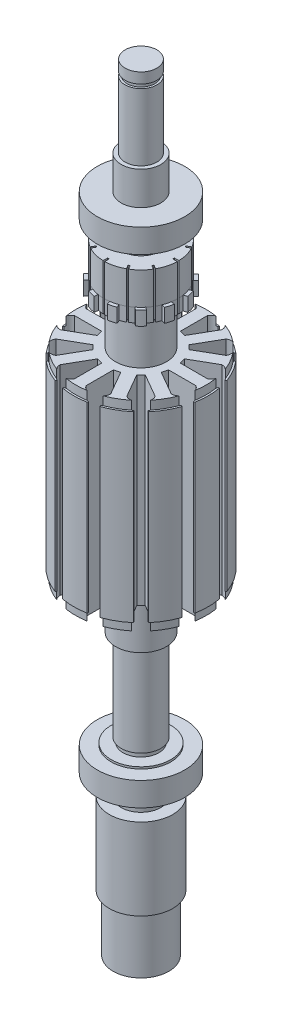
from build123d import *

# Parameters (mm, degrees)
CORTAR_EXTRUIR1_DEPTH  = 12
CORTAR_EXTRUIR9_START  = -3.5
CORTAR_EXTRUIR9_DEPTH  = 3.5
CORTAR_EXTRUIR10_REACH = 134.6


with BuildPart() as part:
    # Croquis1 → Revolución1 (revolve)
    with BuildSketch(Plane.XY):
        Polygon((0, 101.460505057), (-4, 101.460505057), (-4, 98.810505057), (-3.5, 98.810505057), (-3.5, 97.810505057), (-4, 97.810505057), (-4, 80.960505057), (-5, 80.960505057), (-5, 72.560505057), (-11, 72.560505057), (-11, 66.560505057), (-8, 66.560505057), (-8, 65.560505057), (-5, 65.560505057), (-4.5, 65.560505057), (-4.5, 64.360505057), (-5, 64.360505057), (-5, 62.060505057), (-9.35, 62.060505057), (-9.35, 53.910505057), (-10.25, 53.910505057), (-10.25, 50.410505057), (-6.4, 50.410505057), (-6.4, 38.610505057), (-16.45, 38.610505057), (-16.45, 36.460505057), (-16.925, 36.460505057), (-16.925, -9.539494943), (-16.45, -9.539494943), (-16.45, -11.689494943), (-6.4, -11.689494943), (-6.4, -23.489494943), (-5, -23.489494943), (-5, -46.389494943), (-4.5, -46.389494943), (-4.5, -47.589494943), (-5, -47.589494943), (-7.5, -47.589494943), (-7.5, -48.089494943), (-11, -48.089494943), (-11, -54.089494943), (-5, -54.089494943), (-5, -59.289494943), (-8, -59.289494943), (-8, -79.789494943), (-7.016666436, -79.789494943), (-7.016666436, -93.989494943), (-6.624118991, -93.989494943), (-2.282859875, -76.362612781), (0, -76.362612781), align=None)
    revolve(axis=Axis((0, -76.362612781, 0), (0, 1, 0)))

    # Croquis2 → Cortar-Extruir1 (cut)
    with BuildSketch(Plane(origin=(0, 62.060505057, 0), x_dir=(1, 0, 0), z_dir=(0, 1, 0))):
        with BuildLine():
            Line((-0.2, 11.998333218), (-0.2, 8.197560613))
            Line((-0.2, 8.197560613), (0.2, 8.197560613))
            Line((0.2, 8.197560613), (0.2, 11.998333218))
            ThreePointArc((0.2, 11.998333218), (0, 12), (-0.2, 11.998333218))
        make_face()
        with BuildLine():
            Line((4.271985387, 6.99929574), (6.17237169, 10.290861369))
            ThreePointArc((6.17237169, 10.290861369), (6, 10.392304845), (5.825961528, 10.490861369))
            Line((5.825961528, 10.490861369), (3.925575226, 7.19929574))
            Line((3.925575226, 7.19929574), (4.271985387, 6.99929574))
        make_face()
        with BuildLine():
            Line((7.19929574, 3.925575226), (10.490861369, 5.825961528))
            ThreePointArc((10.490861369, 5.825961528), (10.392304845, 6), (10.290861369, 6.17237169))
            Line((10.290861369, 6.17237169), (6.99929574, 4.271985387))
            Line((6.99929574, 4.271985387), (7.19929574, 3.925575226))
        make_face()
        with BuildLine():
            Line((8.197560613, -0.2), (11.998333218, -0.2))
            ThreePointArc((11.998333218, -0.2), (12, 0), (11.998333218, 0.2))
            Line((11.998333218, 0.2), (8.197560613, 0.2))
            Line((8.197560613, 0.2), (8.197560613, -0.2))
        make_face()
        with BuildLine():
            Line((6.99929574, -4.271985387), (10.290861369, -6.17237169))
            ThreePointArc((10.290861369, -6.17237169), (10.392304845, -6), (10.490861369, -5.825961528))
            Line((10.490861369, -5.825961528), (7.19929574, -3.925575226))
            Line((7.19929574, -3.925575226), (6.99929574, -4.271985387))
        make_face()
        with BuildLine():
            Line((3.925575226, -7.19929574), (5.825961528, -10.490861369))
            ThreePointArc((5.825961528, -10.490861369), (6, -10.392304845), (6.17237169, -10.290861369))
            Line((6.17237169, -10.290861369), (4.271985387, -6.99929574))
            Line((4.271985387, -6.99929574), (3.925575226, -7.19929574))
        make_face()
        with BuildLine():
            Line((-0.2, -8.197560613), (-0.2, -11.998333218))
            ThreePointArc((-0.2, -11.998333218), (0, -12), (0.2, -11.998333218))
            Line((0.2, -11.998333218), (0.2, -8.197560613))
            Line((0.2, -8.197560613), (-0.2, -8.197560613))
        make_face()
        with BuildLine():
            Line((-4.271985387, -6.99929574), (-6.17237169, -10.290861369))
            ThreePointArc((-6.17237169, -10.290861369), (-6, -10.392304845), (-5.825961528, -10.490861369))
            Line((-5.825961528, -10.490861369), (-3.925575226, -7.19929574))
            Line((-3.925575226, -7.19929574), (-4.271985387, -6.99929574))
        make_face()
        with BuildLine():
            Line((-7.19929574, -3.925575226), (-10.490861369, -5.825961528))
            ThreePointArc((-10.490861369, -5.825961528), (-10.392304845, -6), (-10.290861369, -6.17237169))
            Line((-10.290861369, -6.17237169), (-6.99929574, -4.271985387))
            Line((-6.99929574, -4.271985387), (-7.19929574, -3.925575226))
        make_face()
        with BuildLine():
            Line((-8.197560613, 0.2), (-11.998333218, 0.2))
            ThreePointArc((-11.998333218, 0.2), (-12, 0), (-11.998333218, -0.2))
            Line((-11.998333218, -0.2), (-8.197560613, -0.2))
            Line((-8.197560613, -0.2), (-8.197560613, 0.2))
        make_face()
        with BuildLine():
            Line((-6.99929574, 4.271985387), (-10.290861369, 6.17237169))
            ThreePointArc((-10.290861369, 6.17237169), (-10.392304845, 6), (-10.490861369, 5.825961528))
            Line((-10.490861369, 5.825961528), (-7.19929574, 3.925575226))
            Line((-7.19929574, 3.925575226), (-6.99929574, 4.271985387))
        make_face()
        with BuildLine():
            Line((-3.925575226, 7.19929574), (-5.825961528, 10.490861369))
            ThreePointArc((-5.825961528, 10.490861369), (-6, 10.392304845), (-6.17237169, 10.290861369))
            Line((-6.17237169, 10.290861369), (-4.271985387, 6.99929574))
            Line((-4.271985387, 6.99929574), (-3.925575226, 7.19929574))
        make_face()
    extrude(amount=-CORTAR_EXTRUIR1_DEPTH, mode=Mode.SUBTRACT)

    # Croquis4 → Cortar-Extruir9 (cut)
    with BuildSketch(Plane(origin=(0, 53.910505057, 0), x_dir=(1, 0, 0), z_dir=(0, 1, 0)).offset(CORTAR_EXTRUIR9_START)):
        with BuildLine():
            Line((1.705844329, 10.23000101), (1.564388643, 9.155538401))
            Line((1.564388643, 9.155538401), (0.118732796, 9.345862604))
            Line((0.118732796, 9.345862604), (0.118732796, 11.707018854))
            Line((0.118732796, 11.707018854), (5.927642229, 10.34859183))
            Line((5.927642229, 10.34859183), (4.648844458, 8.116042081))
            Line((4.648844458, 8.116042081), (3.394817677, 8.636964311))
            Line((3.394817677, 8.636964311), (3.70532732, 9.964766513))
            ThreePointArc((3.70532732, 9.964766513), (2.762797192, 10.528674406), (1.705844329, 10.23000101))
        make_face()
        with BuildLine():
            Line((4.77575692, 8.034388037), (5.956335045, 10.079209332))
            Line((5.956335045, 10.079209332), (10.30778467, 5.998322304))
            Line((10.30778467, 5.998322304), (8.084038439, 4.704276392))
            Line((8.084038439, 4.704276392), (7.258480505, 5.782421666))
            Line((7.258480505, 5.782421666), (8.191290845, 6.777077283))
            ThreePointArc((8.191290845, 6.777077283), (7.656989757, 7.736700908), (6.592305028, 8.006518591))
            Line((6.592305028, 8.006518591), (5.932569507, 7.14673452))
            Line((5.932569507, 7.14673452), (4.77575692, 8.034388037))
        make_face()
        with BuildLine():
            Line((8.153120834, 4.570105684), (10.197942129, 5.750683809))
            Line((10.197942129, 5.750683809), (11.925964533, 0.04080716))
            Line((11.925964533, 0.04080716), (9.35312085, 0.032003642))
            Line((9.35312085, 0.032003642), (9.177239343, 1.378483806))
            Line((9.177239343, 1.378483806), (10.482404603, 1.773475668))
            ThreePointArc((10.482404603, 1.773475668), (10.4994981, 2.871684649), (9.712362919, 3.637695981))
            Line((9.712362919, 3.637695981), (8.711123162, 3.222968895))
            Line((8.711123162, 3.222968895), (8.153120834, 4.570105684))
        make_face()
        with BuildLine():
            Line((9.345862604, -0.118732796), (11.707018854, -0.118732796))
            Line((11.707018854, -0.118732796), (10.34859183, -5.927642229))
            Line((10.34859183, -5.927642229), (8.116042081, -4.648844458))
            Line((8.116042081, -4.648844458), (8.636964311, -3.394817677))
            Line((8.636964311, -3.394817677), (9.964766513, -3.70532732))
            ThreePointArc((9.964766513, -3.70532732), (10.528674406, -2.762797192), (10.23000101, -1.705844329))
            Line((10.23000101, -1.705844329), (9.155538401, -1.564388643))
            Line((9.155538401, -1.564388643), (9.345862604, -0.118732796))
        make_face()
        with BuildLine():
            Line((8.034388037, -4.77575692), (10.079209332, -5.956335045))
            Line((10.079209332, -5.956335045), (5.998322304, -10.30778467))
            Line((5.998322304, -10.30778467), (4.704276392, -8.084038439))
            Line((4.704276392, -8.084038439), (5.782421666, -7.258480505))
            Line((5.782421666, -7.258480505), (6.777077283, -8.191290845))
            ThreePointArc((6.777077283, -8.191290845), (7.736700908, -7.656989757), (8.006518591, -6.592305028))
            Line((8.006518591, -6.592305028), (7.14673452, -5.932569507))
            Line((7.14673452, -5.932569507), (8.034388037, -4.77575692))
        make_face()
        with BuildLine():
            Line((4.570105684, -8.153120834), (5.750683809, -10.197942129))
            Line((5.750683809, -10.197942129), (0.04080716, -11.925964533))
            Line((0.04080716, -11.925964533), (0.032003642, -9.35312085))
            Line((0.032003642, -9.35312085), (1.378483806, -9.177239343))
            Line((1.378483806, -9.177239343), (1.773475668, -10.482404603))
            ThreePointArc((1.773475668, -10.482404603), (2.871684649, -10.4994981), (3.637695981, -9.712362919))
            Line((3.637695981, -9.712362919), (3.222968895, -8.711123162))
            Line((3.222968895, -8.711123162), (4.570105684, -8.153120834))
        make_face()
        with BuildLine():
            Line((-0.118732796, -9.345862604), (-0.118732796, -11.707018854))
            Line((-0.118732796, -11.707018854), (-5.927642229, -10.34859183))
            Line((-5.927642229, -10.34859183), (-4.648844458, -8.116042081))
            Line((-4.648844458, -8.116042081), (-3.394817677, -8.636964311))
            Line((-3.394817677, -8.636964311), (-3.70532732, -9.964766513))
            ThreePointArc((-3.70532732, -9.964766513), (-2.762797192, -10.528674406), (-1.705844329, -10.23000101))
            Line((-1.705844329, -10.23000101), (-1.564388643, -9.155538401))
            Line((-1.564388643, -9.155538401), (-0.118732796, -9.345862604))
        make_face()
        with BuildLine():
            Line((-4.77575692, -8.034388037), (-5.956335045, -10.079209332))
            Line((-5.956335045, -10.079209332), (-10.30778467, -5.998322304))
            Line((-10.30778467, -5.998322304), (-8.084038439, -4.704276392))
            Line((-8.084038439, -4.704276392), (-7.258480505, -5.782421666))
            Line((-7.258480505, -5.782421666), (-8.191290845, -6.777077283))
            ThreePointArc((-8.191290845, -6.777077283), (-7.656989757, -7.736700908), (-6.592305028, -8.006518591))
            Line((-6.592305028, -8.006518591), (-5.932569507, -7.14673452))
            Line((-5.932569507, -7.14673452), (-4.77575692, -8.034388037))
        make_face()
        with BuildLine():
            Line((-8.153120834, -4.570105684), (-10.197942129, -5.750683809))
            Line((-10.197942129, -5.750683809), (-11.925964533, -0.04080716))
            Line((-11.925964533, -0.04080716), (-9.35312085, -0.032003642))
            Line((-9.35312085, -0.032003642), (-9.177239343, -1.378483806))
            Line((-9.177239343, -1.378483806), (-10.482404603, -1.773475668))
            ThreePointArc((-10.482404603, -1.773475668), (-10.4994981, -2.871684649), (-9.712362919, -3.637695981))
            Line((-9.712362919, -3.637695981), (-8.711123162, -3.222968895))
            Line((-8.711123162, -3.222968895), (-8.153120834, -4.570105684))
        make_face()
        with BuildLine():
            Line((-9.345862604, 0.118732796), (-11.707018854, 0.118732796))
            Line((-11.707018854, 0.118732796), (-10.34859183, 5.927642229))
            Line((-10.34859183, 5.927642229), (-8.116042081, 4.648844458))
            Line((-8.116042081, 4.648844458), (-8.636964311, 3.394817677))
            Line((-8.636964311, 3.394817677), (-9.964766513, 3.70532732))
            ThreePointArc((-9.964766513, 3.70532732), (-10.528674406, 2.762797192), (-10.23000101, 1.705844329))
            Line((-10.23000101, 1.705844329), (-9.155538401, 1.564388643))
            Line((-9.155538401, 1.564388643), (-9.345862604, 0.118732796))
        make_face()
        with BuildLine():
            Line((-8.034388037, 4.77575692), (-10.079209332, 5.956335045))
            Line((-10.079209332, 5.956335045), (-5.998322304, 10.30778467))
            Line((-5.998322304, 10.30778467), (-4.704276392, 8.084038439))
            Line((-4.704276392, 8.084038439), (-5.782421666, 7.258480505))
            Line((-5.782421666, 7.258480505), (-6.777077283, 8.191290845))
            ThreePointArc((-6.777077283, 8.191290845), (-7.736700908, 7.656989757), (-8.006518591, 6.592305028))
            Line((-8.006518591, 6.592305028), (-7.14673452, 5.932569507))
            Line((-7.14673452, 5.932569507), (-8.034388037, 4.77575692))
        make_face()
        with BuildLine():
            Line((-4.570105684, 8.153120834), (-5.750683809, 10.197942129))
            Line((-5.750683809, 10.197942129), (-0.04080716, 11.925964533))
            Line((-0.04080716, 11.925964533), (-0.032003642, 9.35312085))
            Line((-0.032003642, 9.35312085), (-1.378483806, 9.177239343))
            Line((-1.378483806, 9.177239343), (-1.773475668, 10.482404603))
            ThreePointArc((-1.773475668, 10.482404603), (-2.871684649, 10.4994981), (-3.637695981, 9.712362919))
            Line((-3.637695981, 9.712362919), (-3.222968895, 8.711123162))
            Line((-3.222968895, 8.711123162), (-4.570105684, 8.153120834))
        make_face()
    extrude(amount=CORTAR_EXTRUIR9_DEPTH, mode=Mode.SUBTRACT)

    # Croquis5 → Cortar-Extruir10 (cut, up to next)
    with BuildSketch(Plane(origin=(0, 38.610505057, 0), x_dir=(1, 0, 0), z_dir=(0, 1, 0)), mode=Mode.PRIVATE) as cortar_extruir10_sk1:
        with BuildLine():
            Line((1.478196291, 8.432321249), (2.936005085, 8.04170256))
            Line((2.936005085, 8.04170256), (6.364406158, 13.979867409))
            ThreePointArc((6.364406158, 13.979867409), (6.150920992, 14.928970981), (5.513598767, 15.663949816))
            Line((5.513598767, 15.663949816), (5.63466054, 15.959518339))
            Line((5.63466054, 15.959518339), (5.513598767, 16.248550154))
            Line((5.513598767, 16.248550154), (3.30245082, 16.792756814))
            Line((3.30245082, 16.792756814), (3.1, 16.638678583))
            Line((3.1, 16.638678583), (3.05705831, 16.322177848))
            ThreePointArc((3.05705831, 16.322177848), (2.137631655, 16.004328618), (1.478196291, 15.289123397))
            Line((1.478196291, 15.289123397), (1.478196291, 8.432321249))
        make_face()
    cortar_extruir10_tool1 = extrude(cortar_extruir10_sk1.sketch, amount=-CORTAR_EXTRUIR10_REACH, mode=Mode.PRIVATE) & part.part
    add(cortar_extruir10_tool1.solids().sort_by_distance((3.45052, 38.610505, -12.874841))[0], mode=Mode.SUBTRACT)
    # Croquis5 → Cortar-Extruir10 (cut, up to next)
    with BuildSketch(Plane(origin=(0, 38.610505057, 0), x_dir=(1, 0, 0), z_dir=(0, 1, 0)), mode=Mode.PRIVATE) as cortar_extruir10_sk2:
        with BuildLine():
            Line((5.496316165, 6.563506269), (8.924717238, 12.501671118))
            ThreePointArc((8.924717238, 12.501671118), (9.853407626, 12.791339326), (10.808579081, 12.606891506))
            Line((10.808579081, 12.606891506), (11.004018043, 12.859518339))
            Line((11.004018043, 12.859518339), (11.256384712, 12.891728591))
            Line((11.256384712, 12.891728591), (12.899191675, 11.314857824))
            Line((12.899191675, 11.314857824), (12.859518339, 11.004018043))
            Line((12.859518339, 11.004018043), (12.606891506, 10.808579081))
            ThreePointArc((12.606891506, 10.808579081), (12.791339326, 9.853407626), (12.501671118, 8.924717238))
            Line((12.501671118, 8.924717238), (6.563506269, 5.496316165))
            Line((6.563506269, 5.496316165), (5.496316165, 6.563506269))
        make_face()
    cortar_extruir10_tool2 = extrude(cortar_extruir10_sk2.sketch, amount=-CORTAR_EXTRUIR10_REACH, mode=Mode.PRIVATE) & part.part
    add(cortar_extruir10_tool2.solids().sort_by_distance((9.425658, 38.610505, -9.424679))[0], mode=Mode.SUBTRACT)
    # Croquis5 → Cortar-Extruir10 (cut, up to next)
    with BuildSketch(Plane(origin=(0, 38.610505057, 0), x_dir=(1, 0, 0), z_dir=(0, 1, 0)), mode=Mode.PRIVATE) as cortar_extruir10_sk3:
        with BuildLine():
            Line((8.04170256, 2.936005085), (13.979867409, 6.364406158))
            ThreePointArc((13.979867409, 6.364406158), (14.928970981, 6.150920992), (15.663949816, 5.513598767))
            Line((15.663949816, 5.513598767), (15.959518339, 5.63466054))
            Line((15.959518339, 5.63466054), (16.194179411, 5.536372102))
            Line((16.194179411, 5.536372102), (16.828456591, 3.349358479))
            Line((16.828456591, 3.349358479), (16.638678583, 3.1))
            Line((16.638678583, 3.1), (16.322177848, 3.05705831))
            ThreePointArc((16.322177848, 3.05705831), (16.004328618, 2.137631655), (15.289123397, 1.478196291))
            Line((15.289123397, 1.478196291), (8.432321249, 1.478196291))
            Line((8.432321249, 1.478196291), (8.04170256, 2.936005085))
        make_face()
    cortar_extruir10_tool3 = extrude(cortar_extruir10_sk3.sketch, amount=-CORTAR_EXTRUIR10_REACH, mode=Mode.PRIVATE) & part.part
    add(cortar_extruir10_tool3.solids().sort_by_distance((12.875199, 38.610505, -3.449182))[0], mode=Mode.SUBTRACT)
    # Croquis5 → Cortar-Extruir10 (cut, up to next)
    with BuildSketch(Plane(origin=(0, 38.610505057, 0), x_dir=(1, 0, 0), z_dir=(0, 1, 0)), mode=Mode.PRIVATE) as cortar_extruir10_sk4:
        with BuildLine():
            Line((8.432321249, -1.478196291), (15.289123397, -1.478196291))
            ThreePointArc((15.289123397, -1.478196291), (16.004328618, -2.137631655), (16.322177848, -3.05705831))
            Line((16.322177848, -3.05705831), (16.638678583, -3.1))
            Line((16.638678583, -3.1), (16.792756814, -3.30245082))
            Line((16.792756814, -3.30245082), (16.248550154, -5.513598767))
            Line((16.248550154, -5.513598767), (15.959518339, -5.63466054))
            Line((15.959518339, -5.63466054), (15.663949816, -5.513598767))
            ThreePointArc((15.663949816, -5.513598767), (14.928970981, -6.150920992), (13.979867409, -6.364406158))
            Line((13.979867409, -6.364406158), (8.04170256, -2.936005085))
            Line((8.04170256, -2.936005085), (8.432321249, -1.478196291))
        make_face()
    cortar_extruir10_tool4 = extrude(cortar_extruir10_sk4.sketch, amount=-CORTAR_EXTRUIR10_REACH, mode=Mode.PRIVATE) & part.part
    add(cortar_extruir10_tool4.solids().sort_by_distance((12.874841, 38.610505, 3.45052))[0], mode=Mode.SUBTRACT)
    # Croquis5 → Cortar-Extruir10 (cut, up to next)
    with BuildSketch(Plane(origin=(0, 38.610505057, 0), x_dir=(1, 0, 0), z_dir=(0, 1, 0)), mode=Mode.PRIVATE) as cortar_extruir10_sk5:
        with BuildLine():
            Line((6.563506269, -5.496316165), (12.501671118, -8.924717238))
            ThreePointArc((12.501671118, -8.924717238), (12.791339326, -9.853407626), (12.606891506, -10.808579081))
            Line((12.606891506, -10.808579081), (12.859518339, -11.004018043))
            Line((12.859518339, -11.004018043), (12.891728591, -11.256384712))
            Line((12.891728591, -11.256384712), (11.314857824, -12.899191675))
            Line((11.314857824, -12.899191675), (11.004018043, -12.859518339))
            Line((11.004018043, -12.859518339), (10.808579081, -12.606891506))
            ThreePointArc((10.808579081, -12.606891506), (9.853407626, -12.791339326), (8.924717238, -12.501671118))
            Line((8.924717238, -12.501671118), (5.496316165, -6.563506269))
            Line((5.496316165, -6.563506269), (6.563506269, -5.496316165))
        make_face()
    cortar_extruir10_tool5 = extrude(cortar_extruir10_sk5.sketch, amount=-CORTAR_EXTRUIR10_REACH, mode=Mode.PRIVATE) & part.part
    add(cortar_extruir10_tool5.solids().sort_by_distance((9.424679, 38.610505, 9.425658))[0], mode=Mode.SUBTRACT)
    # Croquis5 → Cortar-Extruir10 (cut, up to next)
    with BuildSketch(Plane(origin=(0, 38.610505057, 0), x_dir=(1, 0, 0), z_dir=(0, 1, 0)), mode=Mode.PRIVATE) as cortar_extruir10_sk6:
        with BuildLine():
            Line((2.936005085, -8.04170256), (6.364406158, -13.979867409))
            ThreePointArc((6.364406158, -13.979867409), (6.150920992, -14.928970981), (5.513598767, -15.663949816))
            Line((5.513598767, -15.663949816), (5.63466054, -15.959518339))
            Line((5.63466054, -15.959518339), (5.536372102, -16.194179411))
            Line((5.536372102, -16.194179411), (3.349358479, -16.828456591))
            Line((3.349358479, -16.828456591), (3.1, -16.638678583))
            Line((3.1, -16.638678583), (3.05705831, -16.322177848))
            ThreePointArc((3.05705831, -16.322177848), (2.137631655, -16.004328618), (1.478196291, -15.289123397))
            Line((1.478196291, -15.289123397), (1.478196291, -8.432321249))
            Line((1.478196291, -8.432321249), (2.936005085, -8.04170256))
        make_face()
    cortar_extruir10_tool6 = extrude(cortar_extruir10_sk6.sketch, amount=-CORTAR_EXTRUIR10_REACH, mode=Mode.PRIVATE) & part.part
    add(cortar_extruir10_tool6.solids().sort_by_distance((3.449182, 38.610505, 12.875199))[0], mode=Mode.SUBTRACT)
    # Croquis5 → Cortar-Extruir10 (cut, up to next)
    with BuildSketch(Plane(origin=(0, 38.610505057, 0), x_dir=(1, 0, 0), z_dir=(0, 1, 0)), mode=Mode.PRIVATE) as cortar_extruir10_sk7:
        with BuildLine():
            Line((-1.478196291, -8.432321249), (-1.478196291, -15.289123397))
            ThreePointArc((-1.478196291, -15.289123397), (-2.137631655, -16.004328618), (-3.05705831, -16.322177848))
            Line((-3.05705831, -16.322177848), (-3.1, -16.638678583))
            Line((-3.1, -16.638678583), (-3.30245082, -16.792756814))
            Line((-3.30245082, -16.792756814), (-5.513598767, -16.248550154))
            Line((-5.513598767, -16.248550154), (-5.63466054, -15.959518339))
            Line((-5.63466054, -15.959518339), (-5.513598767, -15.663949816))
            ThreePointArc((-5.513598767, -15.663949816), (-6.150920992, -14.928970981), (-6.364406158, -13.979867409))
            Line((-6.364406158, -13.979867409), (-2.936005085, -8.04170256))
            Line((-2.936005085, -8.04170256), (-1.478196291, -8.432321249))
        make_face()
    cortar_extruir10_tool7 = extrude(cortar_extruir10_sk7.sketch, amount=-CORTAR_EXTRUIR10_REACH, mode=Mode.PRIVATE) & part.part
    add(cortar_extruir10_tool7.solids().sort_by_distance((-3.45052, 38.610505, 12.874841))[0], mode=Mode.SUBTRACT)
    # Croquis5 → Cortar-Extruir10 (cut, up to next)
    with BuildSketch(Plane(origin=(0, 38.610505057, 0), x_dir=(1, 0, 0), z_dir=(0, 1, 0)), mode=Mode.PRIVATE) as cortar_extruir10_sk8:
        with BuildLine():
            Line((-5.496316165, -6.563506269), (-8.924717238, -12.501671118))
            ThreePointArc((-8.924717238, -12.501671118), (-9.853407626, -12.791339326), (-10.808579081, -12.606891506))
            Line((-10.808579081, -12.606891506), (-11.004018043, -12.859518339))
            Line((-11.004018043, -12.859518339), (-11.256384712, -12.891728591))
            Line((-11.256384712, -12.891728591), (-12.899191675, -11.314857824))
            Line((-12.899191675, -11.314857824), (-12.859518339, -11.004018043))
            Line((-12.859518339, -11.004018043), (-12.606891506, -10.808579081))
            ThreePointArc((-12.606891506, -10.808579081), (-12.791339326, -9.853407626), (-12.501671118, -8.924717238))
            Line((-12.501671118, -8.924717238), (-6.563506269, -5.496316165))
            Line((-6.563506269, -5.496316165), (-5.496316165, -6.563506269))
        make_face()
    cortar_extruir10_tool8 = extrude(cortar_extruir10_sk8.sketch, amount=-CORTAR_EXTRUIR10_REACH, mode=Mode.PRIVATE) & part.part
    add(cortar_extruir10_tool8.solids().sort_by_distance((-9.425658, 38.610505, 9.424679))[0], mode=Mode.SUBTRACT)
    # Croquis5 → Cortar-Extruir10 (cut, up to next)
    with BuildSketch(Plane(origin=(0, 38.610505057, 0), x_dir=(1, 0, 0), z_dir=(0, 1, 0)), mode=Mode.PRIVATE) as cortar_extruir10_sk9:
        with BuildLine():
            Line((-8.04170256, -2.936005085), (-13.979867409, -6.364406158))
            ThreePointArc((-13.979867409, -6.364406158), (-14.928970981, -6.150920992), (-15.663949816, -5.513598767))
            Line((-15.663949816, -5.513598767), (-15.959518339, -5.63466054))
            Line((-15.959518339, -5.63466054), (-16.194179411, -5.536372102))
            Line((-16.194179411, -5.536372102), (-16.828456591, -3.349358479))
            Line((-16.828456591, -3.349358479), (-16.638678583, -3.1))
            Line((-16.638678583, -3.1), (-16.322177848, -3.05705831))
            ThreePointArc((-16.322177848, -3.05705831), (-16.004328618, -2.137631655), (-15.289123397, -1.478196291))
            Line((-15.289123397, -1.478196291), (-8.432321249, -1.478196291))
            Line((-8.432321249, -1.478196291), (-8.04170256, -2.936005085))
        make_face()
    cortar_extruir10_tool9 = extrude(cortar_extruir10_sk9.sketch, amount=-CORTAR_EXTRUIR10_REACH, mode=Mode.PRIVATE) & part.part
    add(cortar_extruir10_tool9.solids().sort_by_distance((-12.875199, 38.610505, 3.449182))[0], mode=Mode.SUBTRACT)
    # Croquis5 → Cortar-Extruir10 (cut, up to next)
    with BuildSketch(Plane(origin=(0, 38.610505057, 0), x_dir=(1, 0, 0), z_dir=(0, 1, 0)), mode=Mode.PRIVATE) as cortar_extruir10_sk10:
        with BuildLine():
            Line((-8.432321249, 1.478196291), (-15.289123397, 1.478196291))
            ThreePointArc((-15.289123397, 1.478196291), (-16.004328618, 2.137631655), (-16.322177848, 3.05705831))
            Line((-16.322177848, 3.05705831), (-16.638678583, 3.1))
            Line((-16.638678583, 3.1), (-16.792756814, 3.30245082))
            Line((-16.792756814, 3.30245082), (-16.248550154, 5.513598767))
            Line((-16.248550154, 5.513598767), (-15.959518339, 5.63466054))
            Line((-15.959518339, 5.63466054), (-15.663949816, 5.513598767))
            ThreePointArc((-15.663949816, 5.513598767), (-14.928970981, 6.150920992), (-13.979867409, 6.364406158))
            Line((-13.979867409, 6.364406158), (-8.04170256, 2.936005085))
            Line((-8.04170256, 2.936005085), (-8.432321249, 1.478196291))
        make_face()
    cortar_extruir10_tool10 = extrude(cortar_extruir10_sk10.sketch, amount=-CORTAR_EXTRUIR10_REACH, mode=Mode.PRIVATE) & part.part
    add(cortar_extruir10_tool10.solids().sort_by_distance((-12.874841, 38.610505, -3.45052))[0], mode=Mode.SUBTRACT)
    # Croquis5 → Cortar-Extruir10 (cut, up to next)
    with BuildSketch(Plane(origin=(0, 38.610505057, 0), x_dir=(1, 0, 0), z_dir=(0, 1, 0)), mode=Mode.PRIVATE) as cortar_extruir10_sk11:
        with BuildLine():
            Line((-6.563506269, 5.496316165), (-12.501671118, 8.924717238))
            ThreePointArc((-12.501671118, 8.924717238), (-12.791339326, 9.853407626), (-12.606891506, 10.808579081))
            Line((-12.606891506, 10.808579081), (-12.859518339, 11.004018043))
            Line((-12.859518339, 11.004018043), (-12.891728591, 11.256384712))
            Line((-12.891728591, 11.256384712), (-11.314857824, 12.899191675))
            Line((-11.314857824, 12.899191675), (-11.004018043, 12.859518339))
            Line((-11.004018043, 12.859518339), (-10.808579081, 12.606891506))
            ThreePointArc((-10.808579081, 12.606891506), (-9.853407626, 12.791339326), (-8.924717238, 12.501671118))
            Line((-8.924717238, 12.501671118), (-5.496316165, 6.563506269))
            Line((-5.496316165, 6.563506269), (-6.563506269, 5.496316165))
        make_face()
    cortar_extruir10_tool11 = extrude(cortar_extruir10_sk11.sketch, amount=-CORTAR_EXTRUIR10_REACH, mode=Mode.PRIVATE) & part.part
    add(cortar_extruir10_tool11.solids().sort_by_distance((-9.424679, 38.610505, -9.425658))[0], mode=Mode.SUBTRACT)
    # Croquis5 → Cortar-Extruir10 (cut, up to next)
    with BuildSketch(Plane(origin=(0, 38.610505057, 0), x_dir=(1, 0, 0), z_dir=(0, 1, 0)), mode=Mode.PRIVATE) as cortar_extruir10_sk12:
        with BuildLine():
            Line((-2.936005085, 8.04170256), (-6.364406158, 13.979867409))
            ThreePointArc((-6.364406158, 13.979867409), (-6.150920992, 14.928970981), (-5.513598767, 15.663949816))
            Line((-5.513598767, 15.663949816), (-5.63466054, 15.959518339))
            Line((-5.63466054, 15.959518339), (-5.536372102, 16.194179411))
            Line((-5.536372102, 16.194179411), (-3.349358479, 16.828456591))
            Line((-3.349358479, 16.828456591), (-3.1, 16.638678583))
            Line((-3.1, 16.638678583), (-3.05705831, 16.322177848))
            ThreePointArc((-3.05705831, 16.322177848), (-2.137631655, 16.004328618), (-1.478196291, 15.289123397))
            Line((-1.478196291, 15.289123397), (-1.478196291, 8.432321249))
            Line((-1.478196291, 8.432321249), (-2.936005085, 8.04170256))
        make_face()
    cortar_extruir10_tool12 = extrude(cortar_extruir10_sk12.sketch, amount=-CORTAR_EXTRUIR10_REACH, mode=Mode.PRIVATE) & part.part
    add(cortar_extruir10_tool12.solids().sort_by_distance((-3.449182, 38.610505, -12.875199))[0], mode=Mode.SUBTRACT)


solid = part.part
